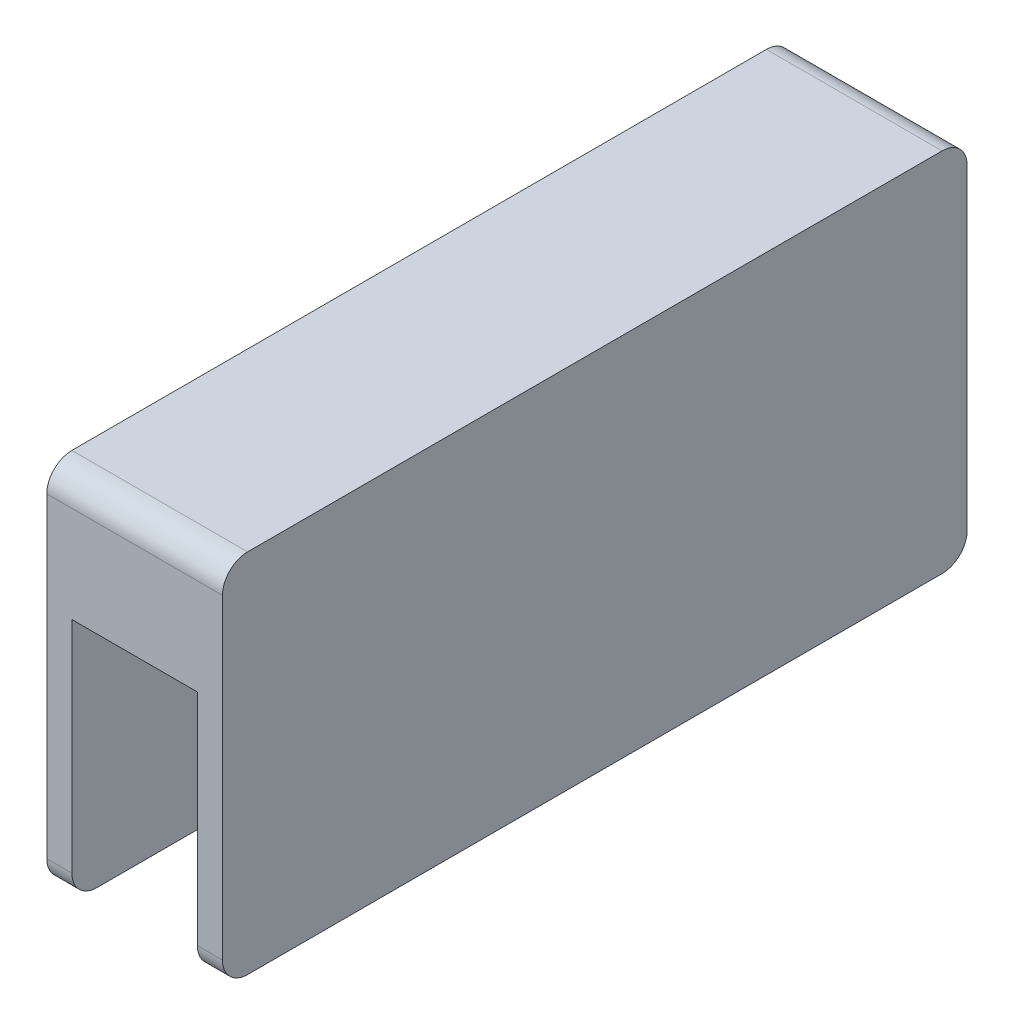
from build123d import *

# Parameters (mm, degrees)
RESSALTO_EXTRUS_O2_DEPTH = 15
RESSALTO_EXTRUS_O3_DEPTH = 3
RESSALTO_EXTRUS_O4_DEPTH = 3


with BuildPart() as part:
    # Esboço2 → Ressalto-extrusão2 (new body)
    with BuildSketch(Plane(origin=(0, 0, 0), x_dir=(0, 0, -1), z_dir=(1, 0, 0))):
        with BuildLine():
            Line((2.90159992, -0.062465938), (-35.09840008, -0.062465938))
            Line((-35.09840008, -0.062465938), (-39.886084903, -0.062465938))
            ThreePointArc((-39.886084903, -0.062465938), (-45.202180234, 1.467638524), (-48.891439328, 5.589707975))
            ThreePointArc((-48.891439328, 5.589707975), (-52.096536948, 9.772081499), (-56.69840008, 12.338743681))
            ThreePointArc((-56.69840008, 12.338743681), (-59.373224015, 11.895603401), (-60.59840008, 9.476926077))
            Line((-60.59840008, 9.476926077), (-60.59840008, 20.976926077))
            ThreePointArc((-60.59840008, 20.976926077), (-59.719720424, 23.09824642), (-57.59840008, 23.976926077))
            Line((-57.59840008, 23.976926077), (25.40159992, 23.976926077))
            ThreePointArc((25.40159992, 23.976926077), (27.522920263, 23.09824642), (28.40159992, 20.976926077))
            Line((28.40159992, 20.976926077), (28.40159992, 9.476926077))
            ThreePointArc((28.40159992, 9.476926077), (27.176423855, 11.895603401), (24.50159992, 12.338743681))
            ThreePointArc((24.50159992, 12.338743681), (19.899736788, 9.772081499), (16.694639168, 5.589707975))
            ThreePointArc((16.694639168, 5.589707975), (13.005380073, 1.467638524), (7.689284743, -0.062465938))
            Line((7.689284743, -0.062465938), (2.90159992, -0.062465938))
        make_face()
    extrude(amount=RESSALTO_EXTRUS_O2_DEPTH)

    # Esboço3 → Ressalto-extrusão3 (add)
    with BuildSketch(Plane.ZY):
        with BuildLine():
            Line((60.59840008, 15.226926077), (60.59840008, 20.976926077))
            ThreePointArc((60.59840008, 20.976926077), (59.719720424, 23.09824642), (57.59840008, 23.976926077))
            Line((57.59840008, 23.976926077), (16.09840008, 23.976926077))
            Line((16.09840008, 23.976926077), (-25.40159992, 23.976926077))
            ThreePointArc((-25.40159992, 23.976926077), (-27.522920263, 23.09824642), (-28.40159992, 20.976926077))
            Line((-28.40159992, 20.976926077), (-28.40159992, 15.226926077))
            Line((-28.40159992, 15.226926077), (-28.40159992, -16.773073923))
            ThreePointArc((-28.40159992, -16.773073923), (-27.522920263, -18.894394267), (-25.40159992, -19.773073923))
            Line((-25.40159992, -19.773073923), (57.59840008, -19.773073923))
            ThreePointArc((57.59840008, -19.773073923), (59.719720424, -18.894394267), (60.59840008, -16.773073923))
            Line((60.59840008, -16.773073923), (60.59840008, 15.226926077))
        make_face()
    extrude(amount=RESSALTO_EXTRUS_O3_DEPTH)

    # Esboço4 → Ressalto-extrusão4 (add)
    with BuildSketch(Plane(origin=(15, 0, 0), x_dir=(0, 0, -1), z_dir=(1, 0, 0))):
        with BuildLine():
            Line((-16.09840008, 23.976926077), (25.40159992, 23.976926077))
            ThreePointArc((25.40159992, 23.976926077), (27.522920263, 23.09824642), (28.40159992, 20.976926077))
            Line((28.40159992, 20.976926077), (28.40159992, 15.226926077))
            Line((28.40159992, 15.226926077), (28.40159992, -16.773073923))
            ThreePointArc((28.40159992, -16.773073923), (27.522920263, -18.894394267), (25.40159992, -19.773073923))
            Line((25.40159992, -19.773073923), (-57.59840008, -19.773073923))
            ThreePointArc((-57.59840008, -19.773073923), (-59.719720424, -18.894394267), (-60.59840008, -16.773073923))
            Line((-60.59840008, -16.773073923), (-60.59840008, 15.226926077))
            Line((-60.59840008, 15.226926077), (-60.59840008, 20.976926077))
            ThreePointArc((-60.59840008, 20.976926077), (-59.719720424, 23.09824642), (-57.59840008, 23.976926077))
            Line((-57.59840008, 23.976926077), (-16.09840008, 23.976926077))
        make_face()
    extrude(amount=RESSALTO_EXTRUS_O4_DEPTH)


solid = part.part
